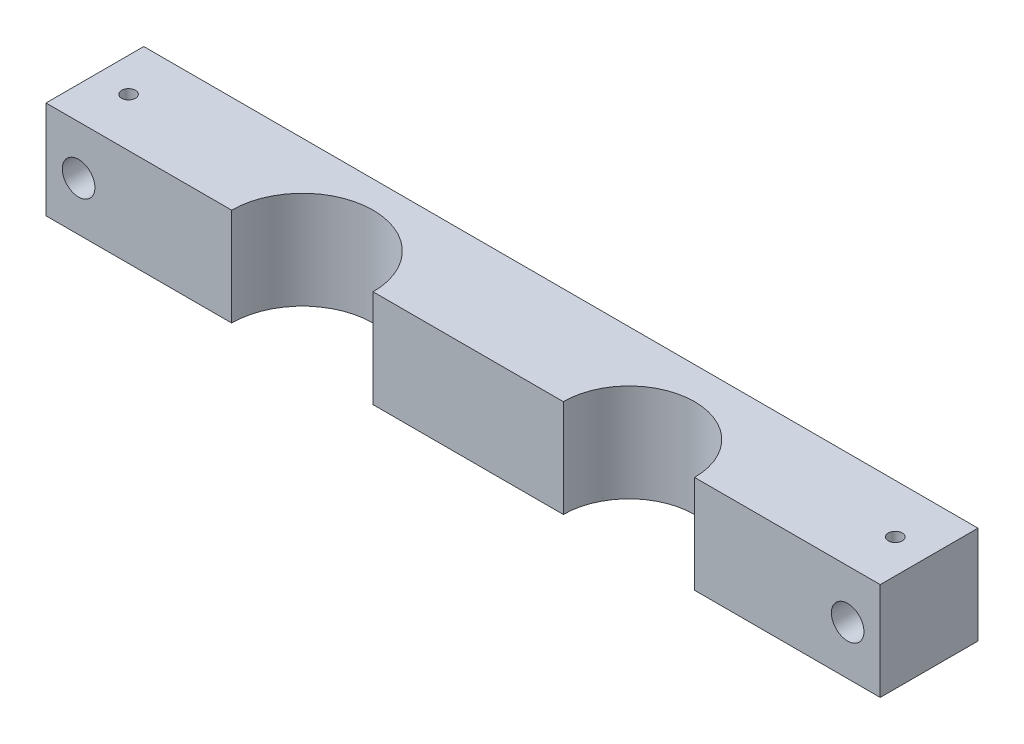
from build123d import *

# Parameters (mm, degrees)
BOSS_EXTRUDE3_DEPTH         = 19.05
F_1_4_0_25_DIAMETER_HOLE1_D = 6.35
F_6_32_TAPPED_HOLE1_REACH   = 166.777
F_6_32_TAPPED_HOLE1_BORE_R  = 1.35255


with BuildPart() as part:
    # Sketch1 → Boss-Extrude3 (new body)
    with BuildSketch(Plane(origin=(0, 0, 0), x_dir=(1, 0, 0), z_dir=(0, 1, 0))):
        with BuildLine():
            Line((63.73495, 0), (100.80625, 0))
            ThreePointArc((100.80625, 0), (113.59515, 12.7889), (126.38405, 0))
            Line((126.38405, 0), (162.56, 0))
            Line((162.56, 0), (162.56, 19.05))
            Line((162.56, 19.05), (0, 19.05))
            Line((0, 19.05), (0, 0))
            Line((0, 0), (36.17595, 0))
            ThreePointArc((36.17595, 0), (49.95545, 13.7795), (63.73495, 0))
        make_face()
    extrude(amount=BOSS_EXTRUDE3_DEPTH)

    # 1/4 (0.25) Diameter Hole1 (through all)
    with Locations(Plane.XY):
        with Locations((6.35, 9.525)):
            f_1_4_0_25_diameter_hole1 = Hole(F_1_4_0_25_DIAMETER_HOLE1_D / 2)

    # #6-32 Tapped Hole1 bore → #6-32 Tapped Hole1 (cut, up to next)
    with BuildSketch(Plane(origin=(0, 19.05, 0), x_dir=(1, 0, 0), z_dir=(0, 1, 0)), mode=Mode.PRIVATE) as f_6_32_tapped_hole1_sk1:
        with Locations((6.578923223, 9.508761569)):
            Circle(F_6_32_TAPPED_HOLE1_BORE_R)
    f_6_32_tapped_hole1_tool1 = extrude(f_6_32_tapped_hole1_sk1.sketch, amount=-F_6_32_TAPPED_HOLE1_REACH, mode=Mode.PRIVATE) & part.part
    f_6_32_tapped_hole1 = f_6_32_tapped_hole1_tool1.solids().sort_by_distance((6.578923, 19.05, -9.508762))[0]
    add(f_6_32_tapped_hole1, mode=Mode.SUBTRACT)

    # Mirror1: 1/4 (0.25) Diameter Hole1, #6-32 Tapped Hole1 across plane
    add(f_1_4_0_25_diameter_hole1.mirror(Plane.ZY.offset(-81.28)), mode=Mode.SUBTRACT)
    add(f_6_32_tapped_hole1.mirror(Plane.ZY.offset(-81.28)), mode=Mode.SUBTRACT)


solid = part.part
